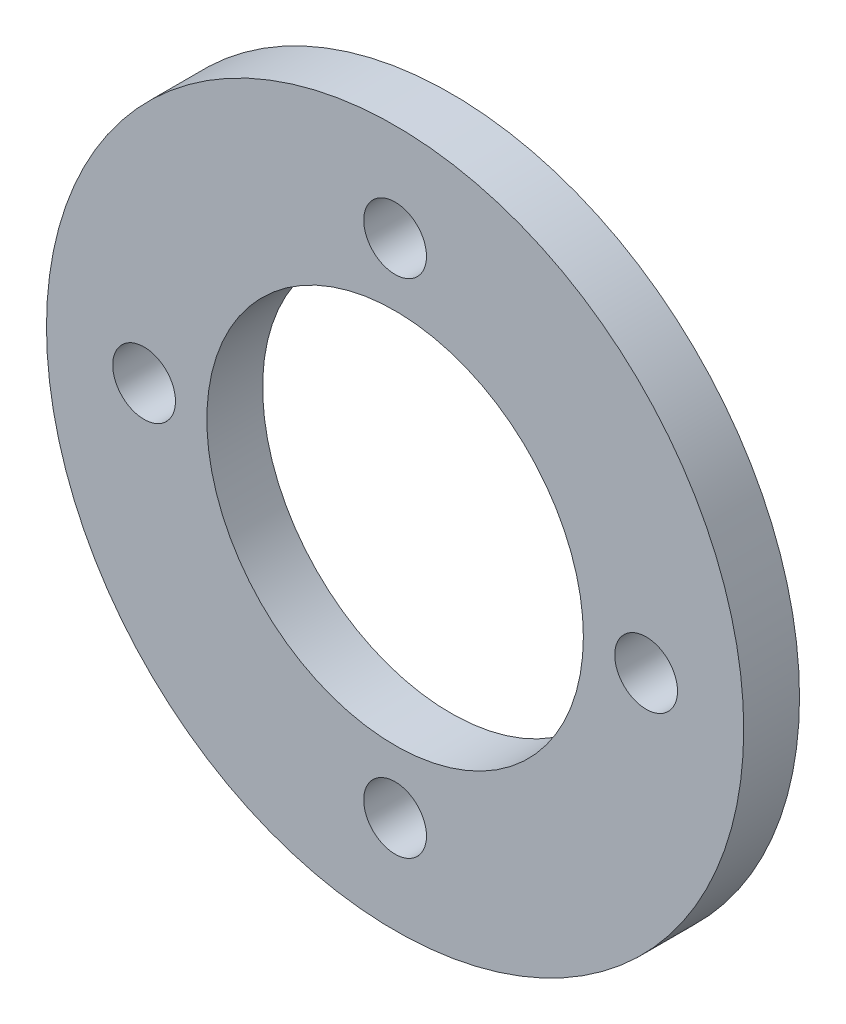
from build123d import *

# Parameters (mm, degrees)
SKETCH1_R           = 25
SKETCH1_R_2         = 13.5
BOSS_EXTRUDE1_DEPTH = 4
SKETCH2_R           = 2.25
CUT_EXTRUDE1_DEPTH  = 5


with BuildPart() as part:
    # Sketch1 → Boss-Extrude1 (new body)
    with BuildSketch(Plane.XY):
        Circle(SKETCH1_R)
        Circle(SKETCH1_R_2, mode=Mode.SUBTRACT)
    extrude(amount=BOSS_EXTRUDE1_DEPTH)

    # Sketch2 → Cut-Extrude1 (cut, through all)
    with BuildSketch(Plane.XY.offset(4)):
        with Locations((0, 18)):
            Circle(SKETCH2_R)
        with Locations((18, 0)):
            Circle(SKETCH2_R)
        with Locations((0, -18)):
            Circle(SKETCH2_R)
        with Locations((-18, 0)):
            Circle(SKETCH2_R)
    extrude(amount=-CUT_EXTRUDE1_DEPTH, mode=Mode.SUBTRACT)


solid = part.part
